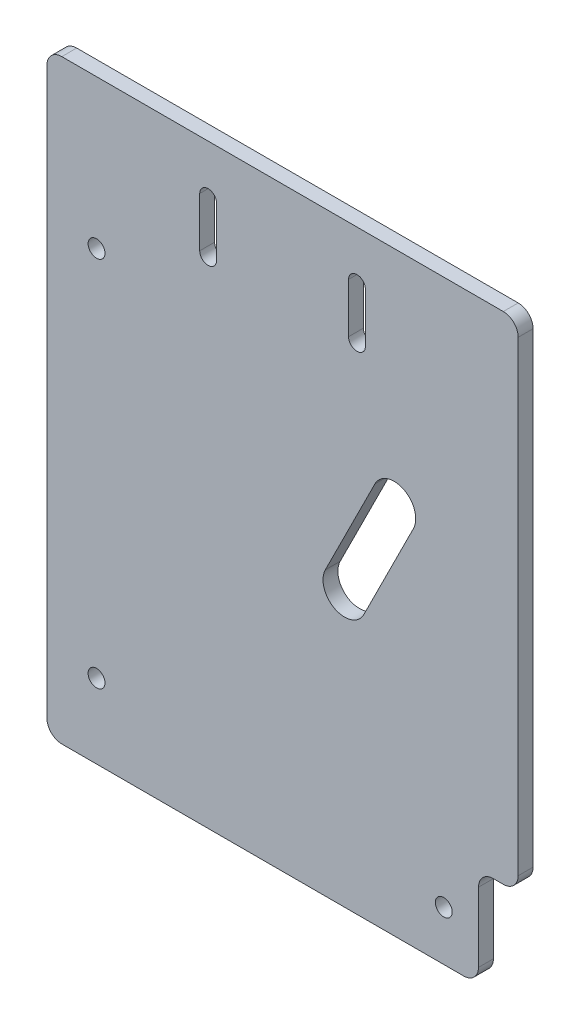
from build123d import *

# Parameters (mm, degrees)
SKETCH1_W           = 95
SKETCH1_H           = 120
SKETCH1_R           = 1.7
BOSS_EXTRUDE1_DEPTH = 3
FILLET1_R           = 3
CUT_EXTRUDE1_DEPTH  = 10
SKETCH3_W           = 8
SKETCH3_H           = 20
CUT_EXTRUDE2_DEPTH  = 4
FILLET2_R           = 3


with BuildPart() as part:
    # Sketch1 → Boss-Extrude1 (new body)
    with BuildSketch(Plane.XY):
        with Locations((47.5, -60)):
            Rectangle(SKETCH1_W, SKETCH1_H)
        with Locations((10, -105)):
            Circle(SKETCH1_R, mode=Mode.SUBTRACT)
        with Locations((80, -110)):
            Circle(SKETCH1_R, mode=Mode.SUBTRACT)
        with Locations((10, -30)):
            Circle(SKETCH1_R, mode=Mode.SUBTRACT)
        with BuildLine():
            Line((56.109241719, -63.05462086), (66.109241719, -43.05462086))
            ThreePointArc((66.109241719, -43.05462086), (70.999425204, -40.766366896), (74.35, -45))
            ThreePointArc((74.35, -45), (74.233633104, -45.999425204), (73.890758281, -46.94537914))
            Line((73.890758281, -46.94537914), (63.890758281, -66.94537914))
            ThreePointArc((63.890758281, -66.94537914), (58.05462086, -68.890758281), (56.109241719, -63.05462086))
        make_face(mode=Mode.SUBTRACT)
    extrude(amount=BOSS_EXTRUDE1_DEPTH)

    # Fillet1
    fillet1_edges = [part.edges().sort_by_distance(p)[0] for p in [
        (0, -120, 1.5),
        (0, 0, 1.5),
        (95, 0, 1.5),
        (95, -120, 1.5),
    ]]
    fillet(fillet1_edges, radius=FILLET1_R)

    # Sketch2 → Cut-Extrude1 (cut)
    with BuildSketch(Plane.XY.offset(3)):
        with BuildLine():
            Line((30.8, -10), (30.8, -20))
            ThreePointArc((30.8, -20), (32.5, -21.7), (34.2, -20))
            Line((34.2, -20), (34.2, -10))
            ThreePointArc((34.2, -10), (32.5, -8.3), (30.8, -10))
        make_face()
        with BuildLine():
            Line((60.8, -10), (60.8, -20))
            ThreePointArc((60.8, -20), (62.5, -21.7), (64.2, -20))
            Line((64.2, -20), (64.2, -10))
            ThreePointArc((64.2, -10), (62.5, -8.3), (60.8, -10))
        make_face()
    extrude(amount=-CUT_EXTRUDE1_DEPTH, mode=Mode.SUBTRACT)

    # Sketch3 → Cut-Extrude2 (cut, through all)
    with BuildSketch(Plane.XY.offset(3)):
        with Locations((91, -110)):
            Rectangle(SKETCH3_W, SKETCH3_H)
    extrude(amount=-CUT_EXTRUDE2_DEPTH, mode=Mode.SUBTRACT)

    # Fillet2
    fillet2_edges = [part.edges().sort_by_distance(p)[0] for p in [
        (95, -100, 1.5),
        (87, -120, 1.5),
        (87, -100, 1.5),
    ]]
    fillet(fillet2_edges, radius=FILLET2_R)


solid = part.part
